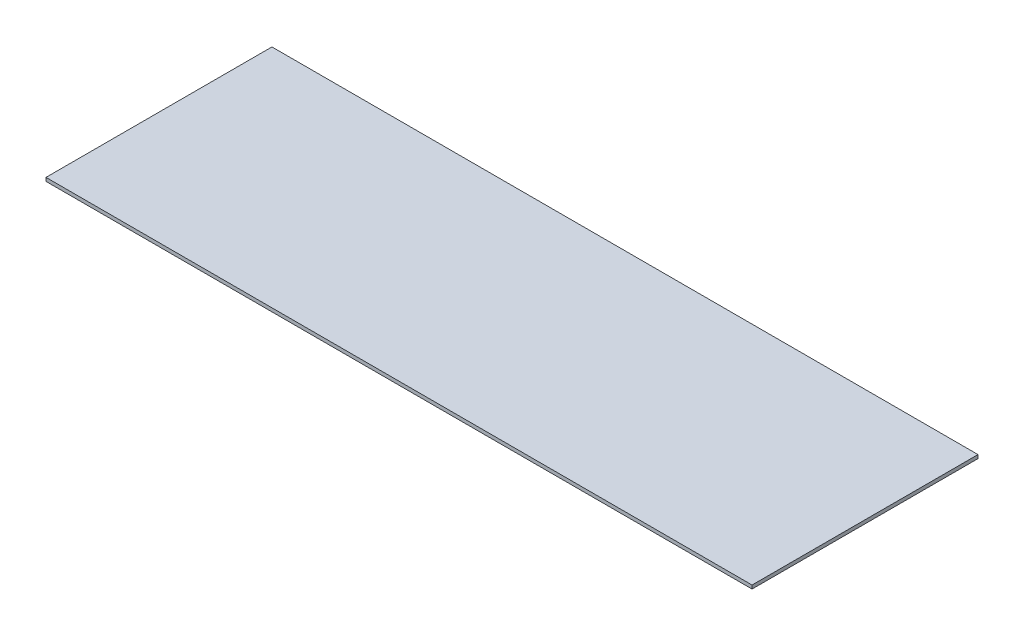
from build123d import *

# Parameters (mm, degrees)
SKETCH1_W           = 635
SKETCH1_H           = 203.2
BOSS_EXTRUDE1_DEPTH = 1.5875


with BuildPart() as part:
    # Sketch1 → Boss-Extrude1 (new body, symmetric)
    with BuildSketch(Plane(origin=(0, 0, 0), x_dir=(1, 0, 0), z_dir=(0, 1, 0))):
        Rectangle(SKETCH1_W, SKETCH1_H)
    extrude(amount=BOSS_EXTRUDE1_DEPTH, both=True)


solid = part.part
